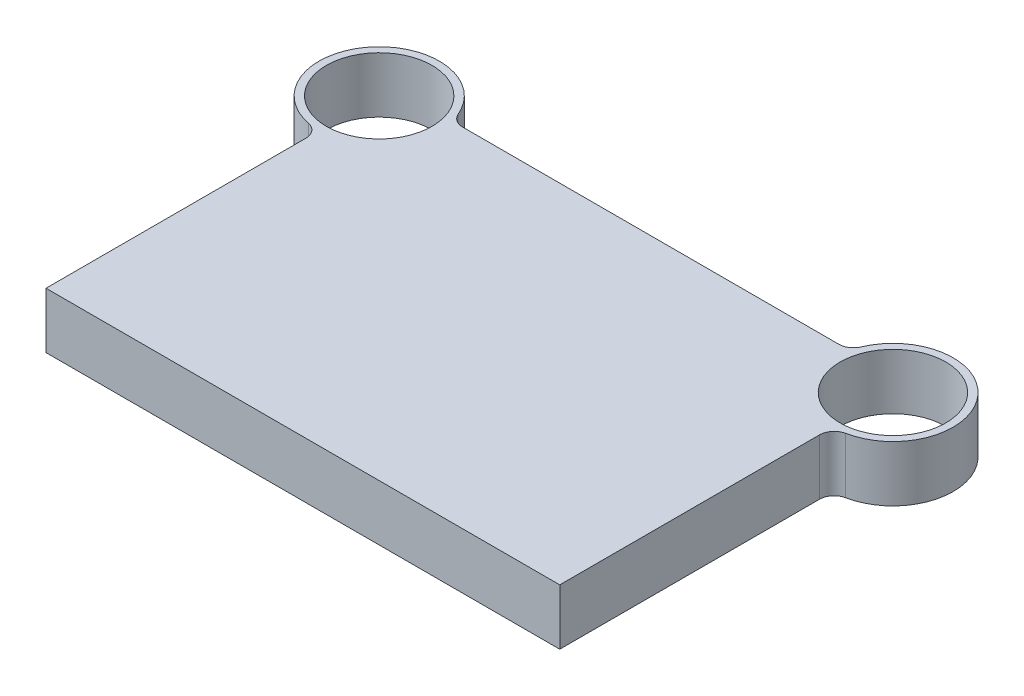
from build123d import *

# Parameters (mm, degrees)
SKETCH1_R           = 36
BOSS_EXTRUDE1_DEPTH = 38
FILLET1_R           = 10


with BuildPart() as part:
    # Sketch1 → Boss-Extrude1 (new body)
    with BuildSketch(Plane(origin=(0, 0, 0), x_dir=(1, 0, 0), z_dir=(0, 1, 0))):
        with BuildLine():
            Line((175, 0), (-175, 0))
            Line((-175, 0), (-175, 186))
            ThreePointArc((-175, 186), (-207.334192428, 252.209125332), (-135.238209296, 237))
            Line((-135.238209296, 237), (135.238209296, 237))
            ThreePointArc((135.238209296, 237), (207.334192428, 252.209125332), (175, 186))
            Line((175, 186), (175, 0))
        make_face()
        with Locations((-175, 227)):
            Circle(SKETCH1_R, mode=Mode.SUBTRACT)
        with Locations((175, 227)):
            Circle(SKETCH1_R, mode=Mode.SUBTRACT)
    extrude(amount=BOSS_EXTRUDE1_DEPTH)

    # Fillet1
    fillet1_edges = [part.edges().sort_by_distance(p)[0] for p in [
        (-175, 19, -186),
        (-135.238209296, 19, -237),
        (135.238209296, 19, -237),
        (175, 19, -186),
    ]]
    fillet(fillet1_edges, radius=FILLET1_R)


solid = part.part
